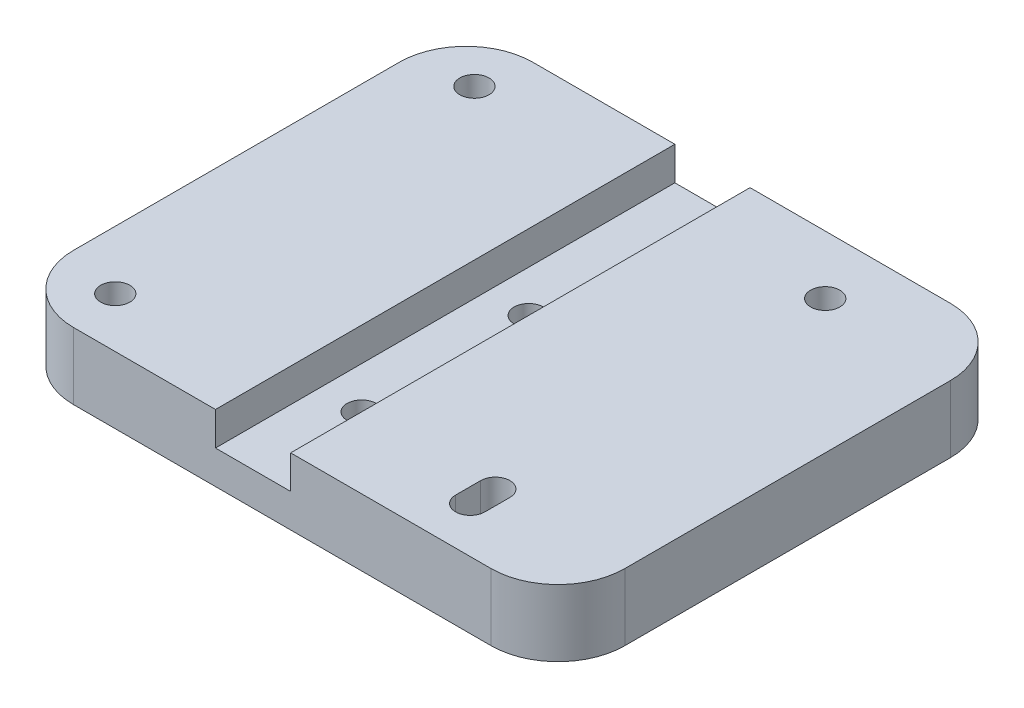
from build123d import *

# Parameters (mm, degrees)
ESBO_O1_W                = 75
ESBO_O1_H                = 4
RESSALTO_EXTRUS_O1_DEPTH = 55
ESBO_O4_R                = 1.75
CORTE_EXTRUS_O2_DEPTH    = 5
ESBO_O5_W                = 32
ESBO_O5_H                = 55
ESBO_O5_R                = 1.75
ESBO_O5_W_2              = 25
RESSALTO_EXTRUS_O2_DEPTH = 4
ESBO_O6_R                = 4
CORTE_EXTRUS_O3_DEPTH    = 4
ESBO_O7_W                = 9
ESBO_O7_H                = 55
CORTE_EXTRUS_O4_DEPTH    = 10
FILETE1_R                = 8


with BuildPart() as part:
    # Esboço1 → Ressalto-extrusão1 (new body)
    with BuildSketch(Plane.XY):
        with Locations((37.5, 2)):
            Rectangle(ESBO_O1_W, ESBO_O1_H)
    extrude(amount=RESSALTO_EXTRUS_O1_DEPTH)

    # Esboço4 → Corte-extrusão2 (cut, through all)
    with BuildSketch(Plane.XZ):
        with Locations((50, 7)):
            Circle(ESBO_O4_R)
        with Locations((30, 22.5)):
            Circle(ESBO_O4_R)
        with Locations((30, 42.5)):
            Circle(ESBO_O4_R)
        with Locations((7, 49)):
            Circle(ESBO_O4_R)
        with Locations((7, 6)):
            Circle(ESBO_O4_R)
        with BuildLine():
            Line((51.75, 49.5), (51.75, 46.5))
            ThreePointArc((51.75, 46.5), (50, 44.75), (48.25, 46.5))
            Line((48.25, 46.5), (48.25, 49.5))
            ThreePointArc((48.25, 49.5), (50, 51.25), (51.75, 49.5))
        make_face()
    extrude(amount=-CORTE_EXTRUS_O2_DEPTH, mode=Mode.SUBTRACT)

    # Esboço5 → Ressalto-extrusão2 (add)
    with BuildSketch(Plane(origin=(0, 4, 0), x_dir=(1, 0, 0), z_dir=(0, 1, 0))):
        with Locations((50, -27.5)):
            Rectangle(ESBO_O5_W, ESBO_O5_H)
        with Locations((50, -7)):
            Circle(ESBO_O5_R, mode=Mode.SUBTRACT)
        with BuildLine():
            Line((48.25, -49.5), (48.25, -46.5))
            ThreePointArc((48.25, -46.5), (50, -44.75), (51.75, -46.5))
            Line((51.75, -46.5), (51.75, -49.5))
            ThreePointArc((51.75, -49.5), (50, -51.25), (48.25, -49.5))
        make_face(mode=Mode.SUBTRACT)
        with Locations((12.5, -27.5)):
            Rectangle(ESBO_O5_W_2, ESBO_O5_H)
        with Locations((7, -49)):
            Circle(ESBO_O5_R, mode=Mode.SUBTRACT)
        with Locations((7, -6)):
            Circle(ESBO_O5_R, mode=Mode.SUBTRACT)
    extrude(amount=RESSALTO_EXTRUS_O2_DEPTH)

    # Esboço6 → Corte-extrusão3 (cut)
    with BuildSketch(Plane.XZ):
        with Locations((50, 7)):
            Circle(ESBO_O6_R)
        with Locations((7, 6)):
            Circle(ESBO_O6_R)
        with Locations((7, 49)):
            Circle(ESBO_O6_R)
        with BuildLine():
            Line((46, 46.5), (46, 49.5))
            ThreePointArc((46, 49.5), (50, 53.5), (54, 49.5))
            Line((54, 49.5), (54, 46.5))
            ThreePointArc((54, 46.5), (50, 42.5), (46, 46.5))
        make_face()
    extrude(amount=-CORTE_EXTRUS_O3_DEPTH, mode=Mode.SUBTRACT)

    # Esboço7 → Corte-extrusão4 (cut)
    with BuildSketch(Plane(origin=(0, 4, 0), x_dir=(1, 0, 0), z_dir=(0, 1, 0))):
        with Locations((70.5, -27.5)):
            Rectangle(ESBO_O7_W, ESBO_O7_H)
    extrude(amount=-CORTE_EXTRUS_O4_DEPTH, mode=Mode.SUBTRACT)

    # Filete1
    filete1_edges = [part.edges().sort_by_distance(p)[0] for p in [
        (0, 4, 55),
        (66, 4, 55),
        (66, 4, 0),
        (0, 4, 0),
    ]]
    fillet(filete1_edges, radius=FILETE1_R)


solid = part.part
